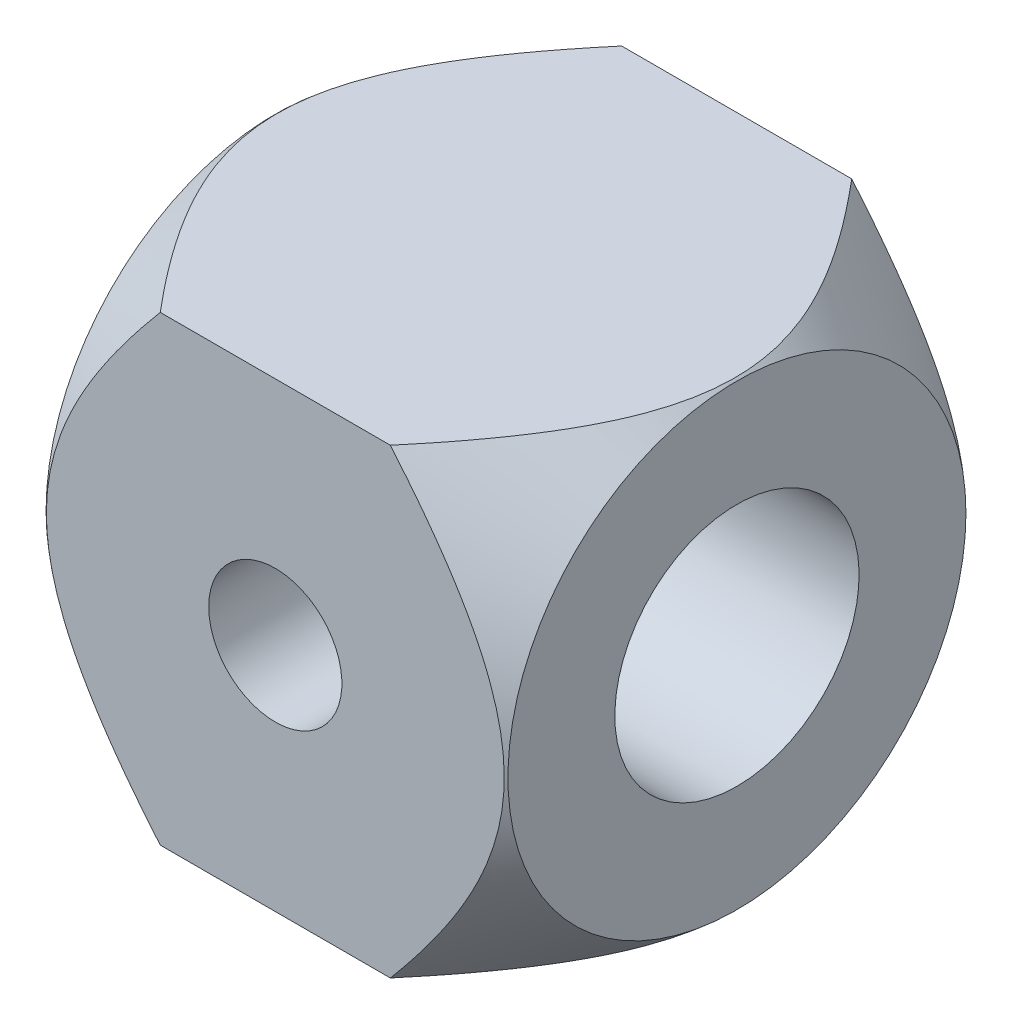
from build123d import *

# Parameters (mm, degrees)
SKETCH3_W           = 6.91642
SKETCH3_H           = 6.9088
BOSS_EXTRUDE2_DEPTH = 3.4544
SKETCH6_R           = 1.8288
CUT_EXTRUDE1_DEPTH  = 9.4488
SKETCH7_R           = 0.99695
CUT_EXTRUDE2_DEPTH  = 9.4488


with BuildPart() as part:
    # Sketch3 → Boss-Extrude2 (new body, symmetric)
    with BuildSketch(Plane.XY):
        Rectangle(SKETCH3_W, SKETCH3_H)
    extrude(amount=BOSS_EXTRUDE2_DEPTH, both=True)

    # Sketch4 → Cut-Revolve2 (revolve, cut)
    with BuildSketch(Plane.XY):
        Polygon((3.45821, 0), (3.45821, 3.429), (0.865442403, 5.604590334), (3.880757522, 5.604590334), (3.880757522, 0), align=None)
        Polygon((-3.880757522, 0), (-3.45821, 0), (-3.45821, 3.429), (-0.865442403, 5.604590334), (-3.880757522, 5.604590334), align=None)
    revolve(axis=Axis((3.880757522, 0, 0), (-1, 0, 0)), mode=Mode.SUBTRACT)

    # Sketch6 → Cut-Extrude1 (cut)
    with BuildSketch(Plane.ZY.offset(3.45821)):
        Circle(SKETCH6_R)
    extrude(amount=-CUT_EXTRUDE1_DEPTH, mode=Mode.SUBTRACT)

    # Sketch7 → Cut-Extrude2 (cut)
    with BuildSketch(Plane(origin=(0, 0, -3.4544), x_dir=(-1, 0, 0), z_dir=(0, 0, -1))):
        Circle(SKETCH7_R)
    extrude(amount=-CUT_EXTRUDE2_DEPTH, mode=Mode.SUBTRACT)


solid = part.part
